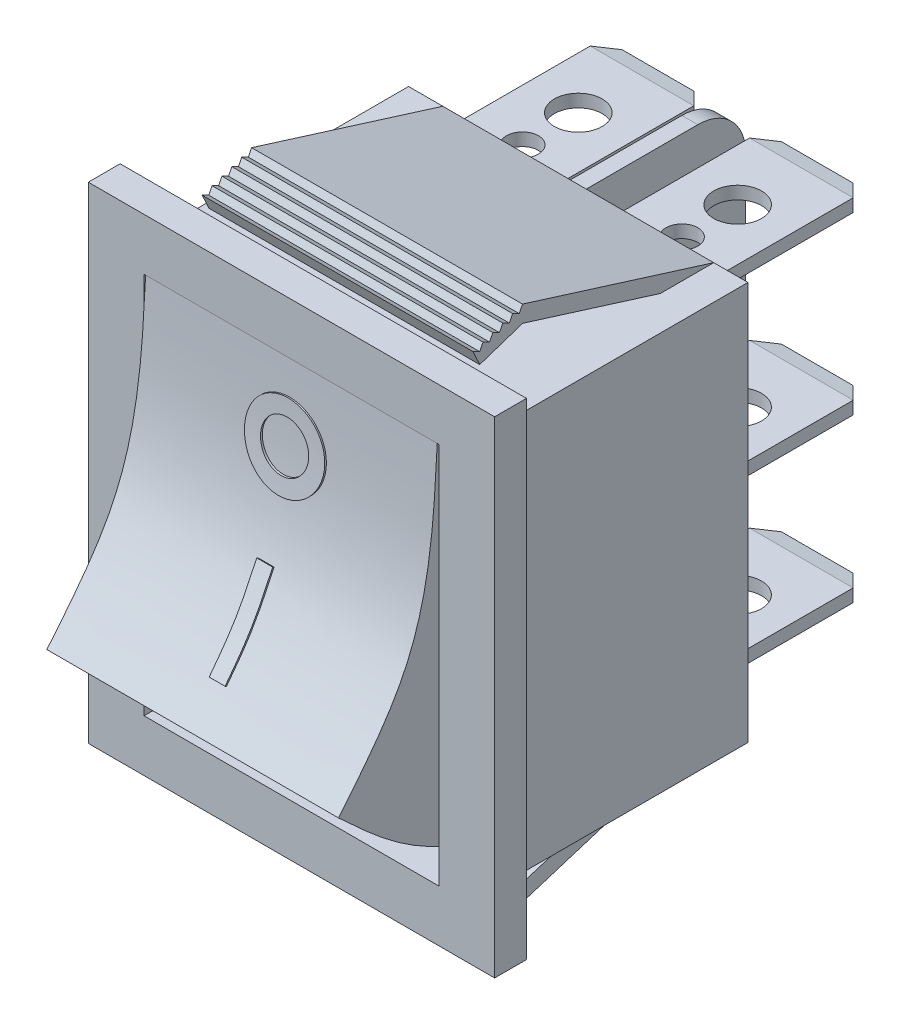
from build123d import *

# Parameters (mm, degrees)
SKETCH_1_W                = 25.5
SKETCH_1_H                = 30.5
EXTRUDE_1_DEPTH           = 2
SKETCH_2_W                = 21.3
SKETCH_2_H                = 25
EXTRUDE_2_DEPTH           = 16
SKETCH_3_W                = 1
SKETCH_3_H                = 25
SKETCH_3_W_2              = 6.5
SKETCH_3_H_2              = 0.8
EXTRUDE_3_DEPTH           = 10
FILLET_1_R                = 3
CHAMFER_3_SIZE            = 1
CHAMFER_3_SIZE2           = 0.2
CHAMFER_3_PART_2_SIZE     = 1
CHAMFER_3_PART_2_SIZE2    = 0.2
CHAMFER_3_PART_3_SIZE     = 1
CHAMFER_3_PART_3_SIZE2    = 0.2
CHAMFER_3_PART_4_SIZE     = 1
CHAMFER_3_PART_4_SIZE2    = 0.2
CHAMFER_3_PART_5_SIZE     = 1
CHAMFER_3_PART_5_SIZE2    = 0.2
CHAMFER_3_PART_6_SIZE     = 1
CHAMFER_3_PART_6_SIZE2    = 0.2
CHAMFER_4_SIZE            = 1
SKETCH_4_R                = 1.5
SKETCH_4_R_2              = 1
CUT_EXTRUDE_4_DEPTH       = 27.65
SKETCH_5_W                = 18.5
SKETCH_5_H                = 24
CUT_EXTRUDE_5_DEPTH       = 5
EXTRUDE_6_DEPTH           = 9.15
EXTRUDE_6_DEPTH_BACK      = 9.15
EXTRUDE_8_DEPTH           = 0.5
EXTRUDE_8_DEPTH_BACK      = 0.5
SKETCH_8_R                = 2.5
SKETCH_8_R_2              = 1.5
EXTRUDE_9_DEPTH           = 1.5
CUT_EXTRUDE_10_DEPTH      = 13.75
CUT_EXTRUDE_10_DEPTH_BACK = 13.75
EXTRUDE_11_DEPTH          = 8.5
EXTRUDE_12_DEPTH          = 1.5


with BuildPart() as part:
    # 草图1 → 拉伸1 (new body)
    with BuildSketch(Plane.XY):
        Rectangle(SKETCH_1_W, SKETCH_1_H)
    extrude(amount=-EXTRUDE_1_DEPTH)

    # 草图2 → 拉伸2 (add)
    with BuildSketch(Plane(origin=(0, 0, -2), x_dir=(-1, 0, 0), z_dir=(0, 0, -1))):
        Rectangle(SKETCH_2_W, SKETCH_2_H)
    extrude(amount=EXTRUDE_2_DEPTH)

    # 草图3 → 拉伸3 (add)
    with BuildSketch(Plane(origin=(0, 0, -18), x_dir=(-1, 0, 0), z_dir=(0, 0, -1))):
        Rectangle(SKETCH_3_W, SKETCH_3_H)
        with Locations((5, 0)):
            Rectangle(SKETCH_3_W_2, SKETCH_3_H_2)
        with Locations((5, 11)):
            Rectangle(SKETCH_3_W_2, SKETCH_3_H_2)
        with Locations((5, -10.2)):
            Rectangle(SKETCH_3_W_2, SKETCH_3_H_2)
    extrude(amount=EXTRUDE_3_DEPTH)

    # 圆角1
    fillet_1_edges = [part.edges().sort_by_distance(p)[0] for p in [
        (0, -12.5, -28),
        (0, 12.5, -28),
    ]]
    fillet(fillet_1_edges, radius=FILLET_1_R)

    # 倒角3
    chamfer_3_edges = [part.edges().sort_by_distance(p)[0] for p in [
        (-5, 0.4, -28),
    ]]
    chamfer_3_side = [part.faces().sort_by_distance(p)[0] for p in [
        (-5, 0.4, -23),
    ]]
    chamfer(chamfer_3_edges, length=CHAMFER_3_SIZE, length2=CHAMFER_3_SIZE2, reference=chamfer_3_side[0])

    # 倒角3 part 2
    chamfer_3_part_2_edges = [part.edges().sort_by_distance(p)[0] for p in [
        (-5, -0.4, -28),
    ]]
    chamfer_3_part_2_side = [part.faces().sort_by_distance(p)[0] for p in [
        (-5, -0.4, -23),
    ]]
    chamfer(chamfer_3_part_2_edges, length=CHAMFER_3_PART_2_SIZE, length2=CHAMFER_3_PART_2_SIZE2, reference=chamfer_3_part_2_side[0])

    # 倒角3 part 3
    chamfer_3_part_3_edges = [part.edges().sort_by_distance(p)[0] for p in [
        (-5, 11.4, -28),
    ]]
    chamfer_3_part_3_side = [part.faces().sort_by_distance(p)[0] for p in [
        (-5, 11.4, -23),
    ]]
    chamfer(chamfer_3_part_3_edges, length=CHAMFER_3_PART_3_SIZE, length2=CHAMFER_3_PART_3_SIZE2, reference=chamfer_3_part_3_side[0])

    # 倒角3 part 4
    chamfer_3_part_4_edges = [part.edges().sort_by_distance(p)[0] for p in [
        (-5, 10.6, -28),
    ]]
    chamfer_3_part_4_side = [part.faces().sort_by_distance(p)[0] for p in [
        (-5, 10.6, -23),
    ]]
    chamfer(chamfer_3_part_4_edges, length=CHAMFER_3_PART_4_SIZE, length2=CHAMFER_3_PART_4_SIZE2, reference=chamfer_3_part_4_side[0])

    # 倒角3 part 5
    chamfer_3_part_5_edges = [part.edges().sort_by_distance(p)[0] for p in [
        (-5, -9.8, -28),
    ]]
    chamfer_3_part_5_side = [part.faces().sort_by_distance(p)[0] for p in [
        (-5, -9.8, -23),
    ]]
    chamfer(chamfer_3_part_5_edges, length=CHAMFER_3_PART_5_SIZE, length2=CHAMFER_3_PART_5_SIZE2, reference=chamfer_3_part_5_side[0])

    # 倒角3 part 6
    chamfer_3_part_6_edges = [part.edges().sort_by_distance(p)[0] for p in [
        (-5, -10.6, -28),
    ]]
    chamfer_3_part_6_side = [part.faces().sort_by_distance(p)[0] for p in [
        (-5, -10.6, -23),
    ]]
    chamfer(chamfer_3_part_6_edges, length=CHAMFER_3_PART_6_SIZE, length2=CHAMFER_3_PART_6_SIZE2, reference=chamfer_3_part_6_side[0])

    # 倒角4
    chamfer_4_edges = [part.edges().sort_by_distance(p)[0] for p in [
        (-8.25, -10.2, -28),
        (-1.75, -10.2, -28),
        (-1.75, 0, -28),
        (-8.25, 0, -28),
        (-8.25, 11, -28),
        (-1.75, 11, -28),
    ]]
    chamfer(chamfer_4_edges, length=CHAMFER_4_SIZE)

    # 草图4 → 拉伸4 (cut, through all)
    with BuildSketch(Plane(origin=(0, 11.4, 0), x_dir=(-1, 0, 0), z_dir=(0, 1, 0))):
        with Locations((5, -23)):
            Circle(SKETCH_4_R)
        with Locations((5, -19.5)):
            Circle(SKETCH_4_R_2)
    extrude(amount=-CUT_EXTRUDE_4_DEPTH, mode=Mode.SUBTRACT)

    # 镜向4: part across plane


with BuildPart() as part_1:
    add(part.part)
    add(part.part.mirror(Plane(origin=(0, 0, 0), x_dir=(0, 0, 1), z_dir=(1, 0, 0))))

    # 草图5 → 拉伸5 (cut)
    with BuildSketch(Plane.XY):
        Rectangle(SKETCH_5_W, SKETCH_5_H)
    extrude(amount=-CUT_EXTRUDE_5_DEPTH, mode=Mode.SUBTRACT)

    # 草图6 → 拉伸6 (add, two sides)
    with BuildSketch(Plane(origin=(0, 0, 0), x_dir=(0, 0, -1), z_dir=(1, 0, 0))) as extrude_6_sk:
        with BuildLine():
            Line((0, 12), (5, 12))
            Line((5, 12), (5, -12))
            add(Edge.make_bspline(
                [(5, -12), (2.559755425, -11.088006961), (-1.611595098, -9.529047389), (-4.854286557, -6.504983315), (-6.2, -5.25)],
                knots=[0, 0, 0, 0, 0.585001083, 1, 1, 1, 1], degree=3))
            add(Edge.make_bspline(
                [(0, 12), (-0.209874313, 8.068657195), (-0.554889277, 1.605874434), (-4.611173562, -3.320401965), (-6.2, -5.25)],
                knots=[0, 0, 0, 0, 0.608304959, 1, 1, 1, 1], degree=3))
        make_face()
    extrude(amount=EXTRUDE_6_DEPTH)
    extrude(extrude_6_sk.sketch, amount=-EXTRUDE_6_DEPTH_BACK)

    # 草图8 → 拉伸9 (add)
    with BuildSketch(Plane.XY):
        with Locations((0, 7.5)):
            Circle(SKETCH_8_R)
        with Locations((0, 7.5)):
            Circle(SKETCH_8_R_2, mode=Mode.SUBTRACT)
    extrude(amount=EXTRUDE_9_DEPTH)

    # 草图9 → 拉伸10 (cut, two sides)
    with BuildSketch(Plane(origin=(0, 0, 0), x_dir=(0, 0, -1), z_dir=(1, 0, 0))) as cut_extrude_10_sk:
        with BuildLine():
            Line((-0.099895342, 12.004573908), (-2.228006296, 12.004573908))
            Line((-2.228006296, 12.004573908), (-2.228006296, 4.264910689))
            Line((-2.228006296, 4.264910689), (-0.938185843, 4.264910689))
            add(Edge.make_bspline(
                [(-0.099895342, 12.004573908), (-0.159300982, 10.707139225), (-0.275275529, 8.107588414), (-0.71644392, 5.544306661), (-0.938185843, 4.264910689)],
                knots=[0, 0, 0, 0, 0.5, 1, 1, 1, 1], degree=3))
        make_face()
    extrude(amount=CUT_EXTRUDE_10_DEPTH, mode=Mode.SUBTRACT)
    extrude(cut_extrude_10_sk.sketch, amount=-CUT_EXTRUDE_10_DEPTH_BACK, mode=Mode.SUBTRACT)

    # 草图10 → 拉伸11 (add, symmetric)
    with BuildSketch(Plane(origin=(0, 0, 0), x_dir=(0, 0, -1), z_dir=(1, 0, 0))):
        Polygon((6, 16.25), (5.793272296, 15.836544592), (5.379816888, 16.043272296), (5.173089184, 15.629816888), (4.759633775, 15.836544592), (4.552906071, 15.423089184), (4.139450663, 15.629816888), (3.932722959, 15.216361479), (3.519267551, 15.423089184), (3.312539847, 15.009633775), (2.899084438, 15.216361479), (3.316227766, 14.301316702), (6.009912217, 15.199211519), (14.647389077, 12.5), (18, 12.5), align=None)
    extrude_11 = extrude(amount=EXTRUDE_11_DEPTH, both=True)

    # 镜向5: 拉伸11 across plane
    add(extrude_11.mirror(Plane.ZX))

    # 草图11 → 拉伸12 (add)
    with BuildSketch(Plane.ZY.offset(10.25)):
        with BuildLine():
            Line((-2, 13.7), (-3, 13.7))
            ThreePointArc((-3, 13.7), (-3.707106781, 13.407106781), (-4, 12.7))
            Line((-4, 12.7), (-4, 12.5))
            Line((-4, 12.5), (-2, 12.5))
            Line((-2, 12.5), (-2, 13.7))
        make_face()
        with BuildLine():
            Line((-2, -12.5), (-4, -12.5))
            Line((-4, -12.5), (-4, -12.7))
            ThreePointArc((-4, -12.7), (-3.707106781, -13.407106781), (-3, -13.7))
            Line((-3, -13.7), (-2, -13.7))
            Line((-2, -13.7), (-2, -12.5))
        make_face()
    extrude(amount=-EXTRUDE_12_DEPTH)


with BuildPart() as body_2:
    # 草图7 → 拉伸8 (new body, two sides)
    with BuildSketch(Plane(origin=(0, 0, 0), x_dir=(0, 0, -1), z_dir=(1, 0, 0))) as extrude_8_sk:
        with BuildLine():
            Line((-1.67732601, 1.792671846), (-1.586887558, 1.75))
            add(Edge.make_bspline(
                [(-4.584241881, -3.25), (-4.119710512, -2.645331447), (-2.930160738, -1.096925058), (-2.09556507, 0.671911956), (-1.586887558, 1.75)],
                knots=[0, 0, 0, 0, 0.390510242, 1, 1, 1, 1], degree=3))
            Line((-4.584241881, -3.25), (-4.663542184, -3.189078231))
            add(Edge.make_bspline(
                [(-4.663542184, -3.189078231), (-4.073386153, -2.420887282), (-2.913091768, -0.861533587), (-2.092156066, 0.913483533), (-1.67732601, 1.792671846)],
                knots=[0, 0, 0, 0, 0.5, 1, 1, 1, 1], degree=3))
        make_face()
    extrude(amount=EXTRUDE_8_DEPTH)
    extrude(extrude_8_sk.sketch, amount=-EXTRUDE_8_DEPTH_BACK)


solid = Compound([part_1.part, body_2.part])
